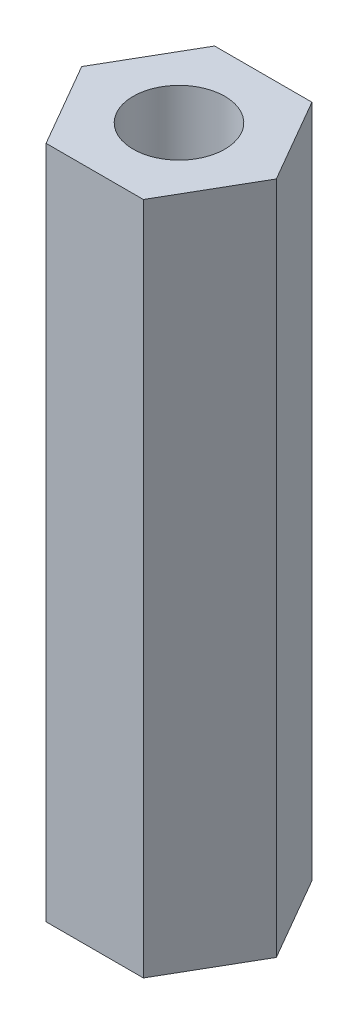
from build123d import *

# Parameters (mm, degrees)
BOSS_EXTRUDE1_DEPTH   = 25.4
F_8_32_TAPPED_HOLE1_D = 3.4544


with BuildPart() as part:
    # Sketch1 → Boss-Extrude1 (new body)
    with BuildSketch(Plane(origin=(0, 0, 0), x_dir=(1, 0, 0), z_dir=(0, 1, 0))):
        Polygon((3.666174209, 0), (1.833087105, 3.175), (-1.833087105, 3.175), (-3.666174209, 0), (-1.833087105, -3.175), (1.833087105, -3.175), align=None)
    extrude(amount=BOSS_EXTRUDE1_DEPTH)

    # #8-32 Tapped Hole1 (through all)
    with Locations(Plane(origin=(0, 0, 0), x_dir=(-1, 0, 0), z_dir=(0, -1, 0))):
        with Locations((0, 0)):
            Hole(F_8_32_TAPPED_HOLE1_D / 2)


solid = part.part
